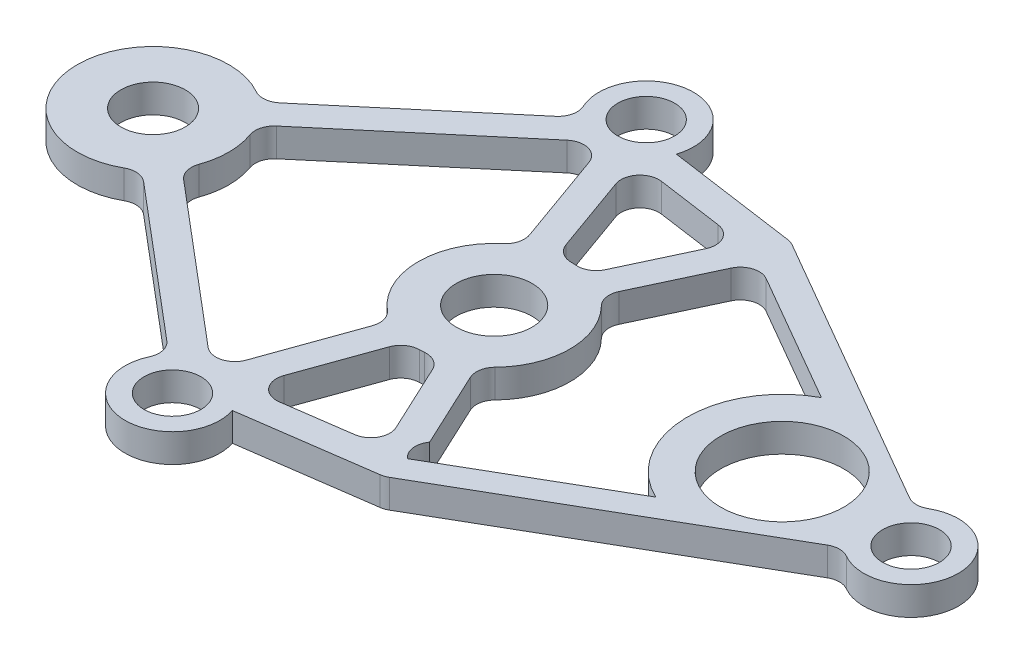
from build123d import *

# Parameters (mm, degrees)
SKETCH_1_R      = 2
SKETCH_1_R_2    = 1.7
SKETCH_1_R_3    = 1.5
SKETCH_1_R_4    = 3.25
EXTRUDE_1_DEPTH = 1.5


with BuildPart() as part:
    # 草图1 → 凸台-拉伸1 (new body)
    with BuildSketch(Plane(origin=(0, 0, 0), x_dir=(1, 0, 0), z_dir=(0, 1, 0))):
        with BuildLine():
            Line((19.75, 2.165063509), (5.096488448, 10.625272348))
            ThreePointArc((5.096488448, 10.625272348), (4.922427124, 10.704637858), (4.736437674, 10.749405626))
            Line((4.736437674, 10.749405626), (-2.101908222, 11.7159388))
            ThreePointArc((-2.101908222, 11.7159388), (-4.61878361, 14.995906411), (-6.744553684, 11.449929699))
            ThreePointArc((-6.744553684, 11.449929699), (-6.675732942, 10.813623622), (-7.006838923, 10.265909693))
            Line((-7.006838923, 10.265909693), (-14.905573539, 3.595069524))
            ThreePointArc((-14.905573539, 3.595069524), (-15.456234647, 3.363542696), (-16.040639512, 3.487249128))
            ThreePointArc((-16.040639512, 3.487249128), (-22, 0), (-16.040639512, -3.487249128))
            ThreePointArc((-16.040639512, -3.487249128), (-15.456234647, -3.363542696), (-14.905573539, -3.595069524))
            Line((-14.905573539, -3.595069524), (-7.006838923, -10.265909693))
            ThreePointArc((-7.006838923, -10.265909693), (-6.675732942, -10.813623622), (-6.744553684, -11.449929699))
            ThreePointArc((-6.744553684, -11.449929699), (-4.61878361, -14.995906411), (-2.101908222, -11.7159388))
            Line((-2.101908222, -11.7159388), (4.736437674, -10.749405626))
            ThreePointArc((4.736437674, -10.749405626), (4.922427124, -10.704637858), (5.096488448, -10.625272348))
            Line((5.096488448, -10.625272348), (19.75, -2.165063509))
            ThreePointArc((19.75, -2.165063509), (20.25, -2.031088913), (20.75, -2.165063509))
            ThreePointArc((20.75, -2.165063509), (24.5, 0), (20.75, 2.165063509))
            ThreePointArc((20.75, 2.165063509), (20.25, 2.031088913), (19.75, 2.165063509))
        make_face()
        Circle(SKETCH_1_R, mode=Mode.SUBTRACT)
        with Locations((-18, 0)):
            Circle(SKETCH_1_R_2, mode=Mode.SUBTRACT)
        with Locations((22, 0)):
            Circle(SKETCH_1_R_3, mode=Mode.SUBTRACT)
        with Locations((-4.47577596, 12.5)):
            Circle(SKETCH_1_R_3, mode=Mode.SUBTRACT)
        with Locations((-4.47577596, -12.5)):
            Circle(SKETCH_1_R_3, mode=Mode.SUBTRACT)
        with Locations((15.2, 0)):
            Circle(SKETCH_1_R_4, mode=Mode.SUBTRACT)
        with BuildLine():
            Line((2.23143448, 9.588554578), (-1.256530939, 10.081544307))
            ThreePointArc((-1.256530939, 10.081544307), (-2.171731289, 9.72303877), (-2.33794765, 8.754281823))
            Line((-2.33794765, 8.754281823), (-0.872808817, 4.662424773))
            ThreePointArc((-0.872808817, 4.662424773), (-0.512657064, 4.185850496), (0.054926934, 3.999622861))
            ThreePointArc((0.054926934, 3.999622861), (0.187612888, 3.995597753), (0.320092213, 3.987172052))
            ThreePointArc((0.320092213, 3.987172052), (0.902629068, 4.119395878), (1.305852753, 4.56012594))
            Line((1.305852753, 4.56012594), (2.997222742, 8.174556771))
            ThreePointArc((2.997222742, 8.174556771), (2.970810351, 9.074617878), (2.23143448, 9.588554578))
        make_face(mode=Mode.SUBTRACT)
        with BuildLine():
            Line((12.853062501, 4.414961424), (5.956182941, 8.396876694))
            ThreePointArc((5.956182941, 8.396876694), (5.156119776, 8.484770625), (4.550445454, 7.954690416))
            Line((4.550445454, 7.954690416), (2.664458984, 3.924367251))
            ThreePointArc((2.664458984, 3.924367251), (2.584431714, 3.332397688), (2.856157177, 2.800422501))
            ThreePointArc((2.856157177, 2.800422501), (4, 0), (2.856157177, -2.800422501))
            ThreePointArc((2.856157177, -2.800422501), (2.584431714, -3.332397688), (2.664458984, -3.924367251))
            Line((2.664458984, -3.924367251), (4.550445454, -7.954690416))
            ThreePointArc((4.550445454, -7.954690416), (4.374221674, -8.659373504), (4.721405489, -9.297414626))
            Line((4.721405489, -9.297414626), (13.026112738, -4.50268966))
            ThreePointArc((13.026112738, -4.50268966), (10.200941154, -0.097008541), (12.853062501, 4.414961424))
        make_face(mode=Mode.SUBTRACT)
        with BuildLine():
            Line((-2.33794765, -8.754281823), (-0.872808817, -4.662424773))
            ThreePointArc((-0.872808817, -4.662424773), (-0.512657064, -4.185850496), (0.054926934, -3.999622861))
            ThreePointArc((0.054926934, -3.999622861), (0.187612888, -3.995597753), (0.320092213, -3.987172052))
            ThreePointArc((0.320092213, -3.987172052), (0.902629068, -4.119395878), (1.305852753, -4.56012594))
            Line((1.305852753, -4.56012594), (2.997222742, -8.174556771))
            ThreePointArc((2.997222742, -8.174556771), (2.970810351, -9.074617878), (2.23143448, -9.588554578))
            Line((2.23143448, -9.588554578), (-1.256530939, -10.081544307))
            ThreePointArc((-1.256530939, -10.081544307), (-2.171731289, -9.72303877), (-2.33794765, -8.754281823))
        make_face(mode=Mode.SUBTRACT)
        with BuildLine():
            Line((-5.622052564, 9.472053038), (-13.937734763, 2.449081695))
            ThreePointArc((-13.937734763, 2.449081695), (-14.258158429, 1.944937864), (-14.23400713, 1.348071847))
            ThreePointArc((-14.23400713, 1.348071847), (-14, 0), (-14.23400713, -1.348071847))
            ThreePointArc((-14.23400713, -1.348071847), (-14.258158429, -1.944937864), (-13.937734763, -2.449081695))
            Line((-13.937734763, -2.449081695), (-5.622052564, -9.472053038))
            ThreePointArc((-5.622052564, -9.472053038), (-4.717022681, -9.673722513), (-4.035359228, -9.045164955))
            Line((-4.035359228, -9.045164955), (-2.285010045, -4.156769069))
            ThreePointArc((-2.285010045, -4.156769069), (-2.260804326, -3.559905256), (-2.581182025, -3.055732213))
            ThreePointArc((-2.581182025, -3.055732213), (-4, 0), (-2.581182025, 3.055732213))
            ThreePointArc((-2.581182025, 3.055732213), (-2.260804326, 3.559905256), (-2.285010045, 4.156769069))
            Line((-2.285010045, 4.156769069), (-4.035359228, 9.045164955))
            ThreePointArc((-4.035359228, 9.045164955), (-4.717022681, 9.673722513), (-5.622052564, 9.472053038))
        make_face(mode=Mode.SUBTRACT)
    extrude(amount=EXTRUDE_1_DEPTH)


solid = part.part
